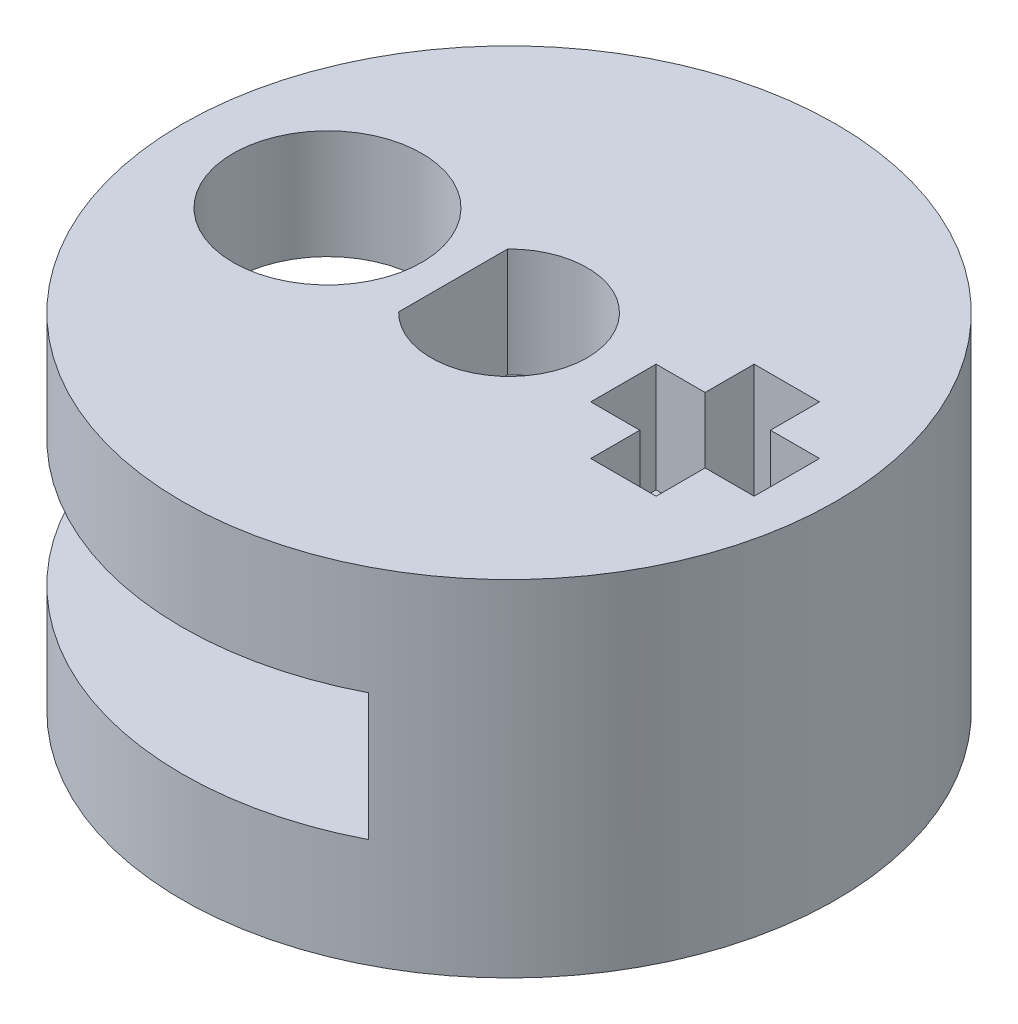
from build123d import *

# Parameters (mm, degrees)
SKETCH1_R           = 9
SKETCH1_R_2         = 2.6
BOSS_EXTRUDE1_DEPTH = 3
BOSS_EXTRUDE2_DEPTH = 3.5
SKETCH4_R           = 2.6
BOSS_EXTRUDE3_DEPTH = 3
CUT_EXTRUDE1_DEPTH  = 10


with BuildPart() as part:
    # Sketch1 → Boss-Extrude1 (new body)
    with BuildSketch(Plane(origin=(0, 0, 0), x_dir=(1, 0, 0), z_dir=(0, 1, 0))):
        Circle(SKETCH1_R)
        with Locations((-5, 0)):
            Circle(SKETCH1_R_2, mode=Mode.SUBTRACT)
        with BuildLine():
            Line((-1.54029218, 1.5), (-1.54029218, -1.5))
            ThreePointArc((-1.54029218, -1.5), (2.15, 0), (-1.54029218, 1.5))
        make_face(mode=Mode.SUBTRACT)
    extrude(amount=BOSS_EXTRUDE1_DEPTH)

    # Sketch2 → Boss-Extrude2 (add)
    with BuildSketch(Plane.XZ):
        with BuildLine():
            Line((4.123105626, 8), (4.123105626, -8))
            ThreePointArc((4.123105626, -8), (9, 0), (4.123105626, 8))
        make_face()
    extrude(amount=BOSS_EXTRUDE2_DEPTH)

    # Sketch4 → Boss-Extrude3 (add)
    with BuildSketch(Plane.XZ.offset(3.5)):
        with BuildLine():
            ThreePointArc((4.123105626, 8), (-9, 0), (4.123105626, -8))
            ThreePointArc((4.123105626, -8), (9, 0), (4.123105626, 8))
        make_face()
        with Locations((-5, 0)):
            Circle(SKETCH4_R, mode=Mode.SUBTRACT)
    extrude(amount=BOSS_EXTRUDE3_DEPTH)

    # Sketch5 → Cut-Extrude1 (cut)
    with BuildSketch(Plane(origin=(0, 3, 0), x_dir=(1, 0, 0), z_dir=(0, 1, 0))):
        Polygon((3.25, 0.798435283), (3.25, -1.001564717), (4.6, -1.001564717), (4.6, -2.351564717), (6.4, -2.351564717), (6.4, -1.001564717), (7.75, -1.001564717), (7.75, 0.798435283), (6.4, 0.798435283), (6.4, 2.148435283), (4.6, 2.148435283), (4.6, 0.798435283), align=None)
    extrude(amount=-CUT_EXTRUDE1_DEPTH, mode=Mode.SUBTRACT)


solid = part.part
